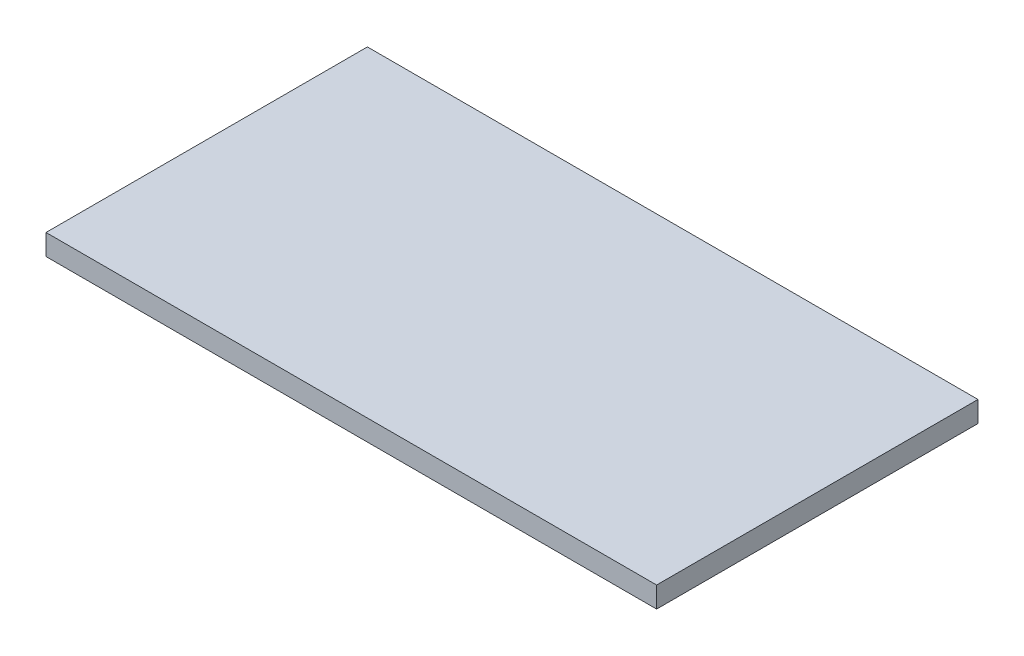
from build123d import *

# Parameters (mm, degrees)
SKETCH1_W           = 185.853871684
SKETCH1_H           = 97.822208048
BOSS_EXTRUDE1_DEPTH = 6.35


with BuildPart() as part:
    # Sketch1 → Boss-Extrude1 (new body)
    with BuildSketch(Plane(origin=(0, 0, 0), x_dir=(1, 0, 0), z_dir=(0, 1, 0))):
        with Locations((-8.723594491, -38.378281073)):
            Rectangle(SKETCH1_W, SKETCH1_H)
    extrude(amount=BOSS_EXTRUDE1_DEPTH)


solid = part.part
